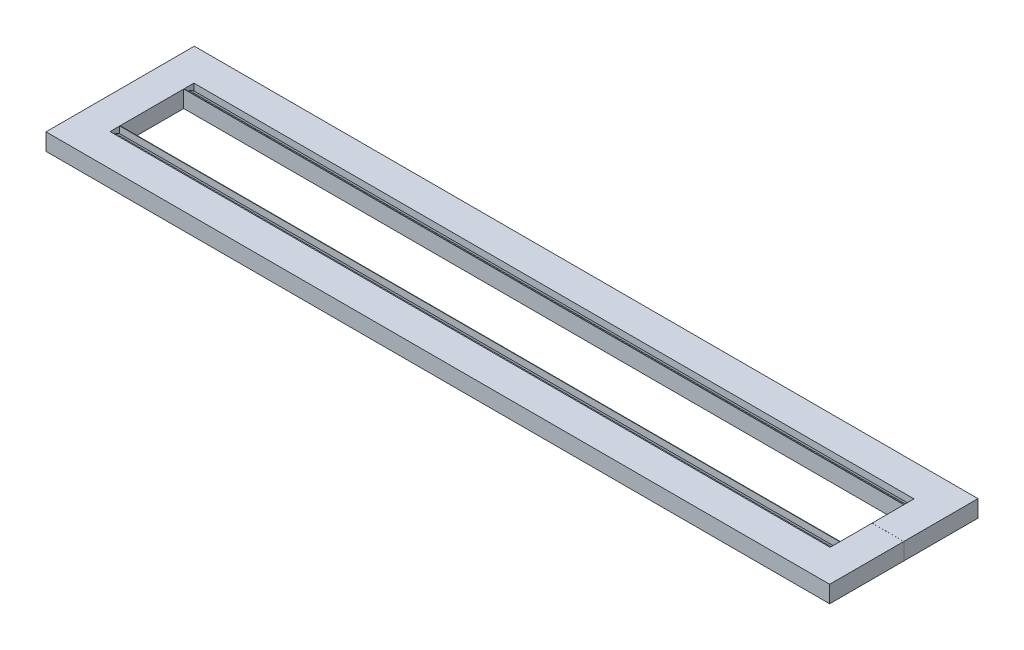
from build123d import *

# Parameters (mm, degrees)
BOSS_EXTRUDE1_DEPTH = 10.16
CUT_EXTRUDE1_DEPTH  = 469.9
SKETCH7_W           = 12.402912868
SKETCH7_H           = 5.692085864
BOSS_EXTRUDE2_DEPTH = 19.05
SKETCH8_W           = 44.473666897
SKETCH8_H           = 10.16
BOSS_EXTRUDE3_DEPTH = 19.05
SKETCH11_R          = 5.7912
CUT_EXTRUDE2_DEPTH  = 3.81


with BuildPart() as part:
    # Sketch1 → Boss-Extrude1 (new body)
    with BuildSketch(Plane(origin=(0, 0, 0), x_dir=(1, 0, 0), z_dir=(0, 1, 0))):
        Polygon((16.038025544, 57.472460937), (-434.826171875, 57.472460937), (-434.826171875, 13.022460937), (-415.790369294, 13.022460937), (-415.790369294, 32.072460937), (16.038025544, 32.072460938), align=None)
        Polygon((35.073828125, 57.472460938), (16.038025544, 57.472460937), (16.038025544, 32.072460938), (16.038025544, 13.022460938), (35.073828125, 13.022460938), align=None)
    extrude(amount=BOSS_EXTRUDE1_DEPTH)

    # Sketch3 → Cut-Extrude1 (cut)
    with BuildSketch(Plane(origin=(35.073828125, 0, 0), x_dir=(0, 0, -1), z_dir=(1, 0, 0))):
        Polygon((38.155998325, 6.152693314), (38.155998325, 10.16), (32.33892355, 10.16), (32.33892355, 6.152693314), (35.247460938, 7.831938158), align=None)
    extrude(amount=-CUT_EXTRUDE1_DEPTH, mode=Mode.SUBTRACT)

    # Sketch7 → Boss-Extrude2 (add)
    with BuildSketch(Plane(origin=(35.073828125, 0, 0), x_dir=(0, 0, -1), z_dir=(1, 0, 0))):
        with Locations((34.557393907, 7.313957068)):
            Rectangle(SKETCH7_W, SKETCH7_H)
    extrude(amount=-BOSS_EXTRUDE2_DEPTH)

    # Sketch8 → Boss-Extrude3 (add)
    with BuildSketch(Plane.ZY.offset(434.826171875)):
        with Locations((-35.23562749, 5.08)):
            Rectangle(SKETCH8_W, SKETCH8_H)
    extrude(amount=-BOSS_EXTRUDE3_DEPTH)

    # Mirror1: part across plane


with BuildPart() as part_1:
    add(part.part)
    add(part.part.mirror(Plane(origin=(-415.776171875, 10.16, -12.998794041), x_dir=(1, 0, 0), z_dir=(0, 0, 1))))

    # Sketch11 → Cut-Extrude2 (cut)
    with BuildSketch(Plane.XZ):
        with Locations((-425.156251148, 10.226790326)):
            Circle(SKETCH11_R)
        with Locations((25.403907398, -36.248045304)):
            Circle(SKETCH11_R)
        with Locations((25.403907398, 10.226790326)):
            Circle(SKETCH11_R)
        with Locations((-425.156251148, -36.248045304)):
            Circle(SKETCH11_R)
    extrude(amount=-CUT_EXTRUDE2_DEPTH, mode=Mode.SUBTRACT)


solid = part_1.part
